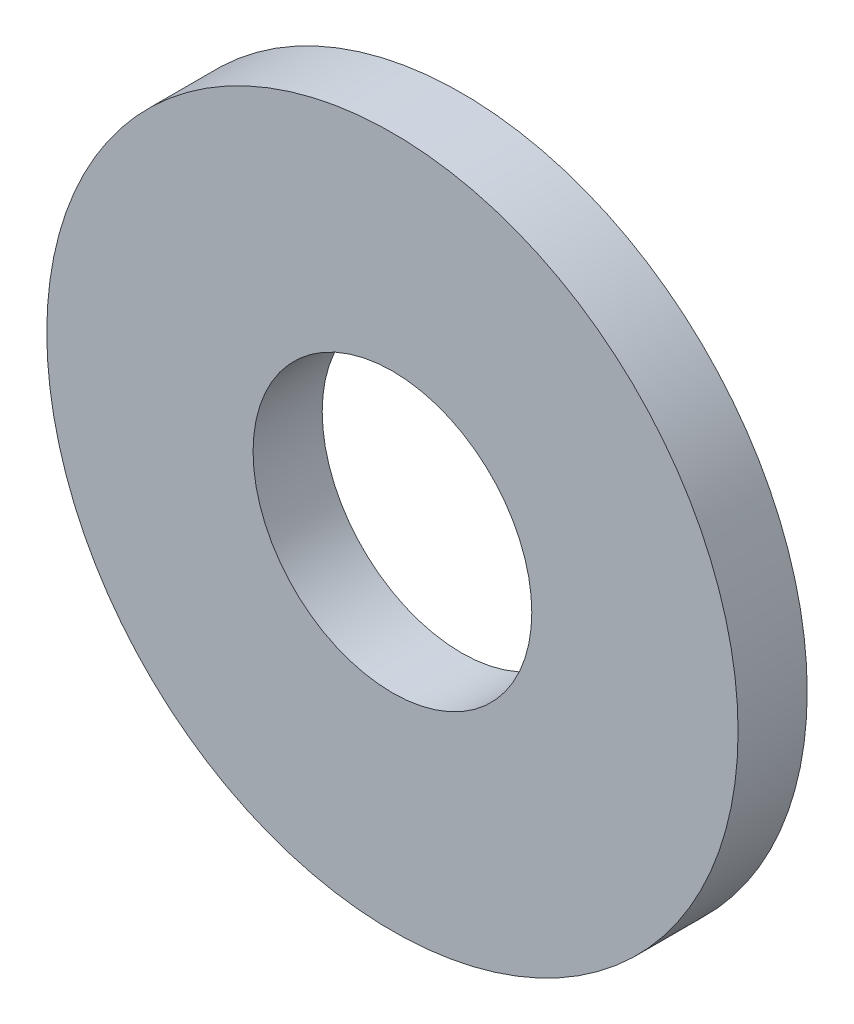
from build123d import *

# Parameters (mm, degrees)
SKETCH1_R      = 7.9375
SKETCH1_R_2    = 3.2004
EXTRUDE1_DEPTH = 0.79375


with BuildPart() as part:
    # Sketch1 → Extrude1 (new body, symmetric)
    with BuildSketch(Plane.XY):
        Circle(SKETCH1_R)
        Circle(SKETCH1_R_2, mode=Mode.SUBTRACT)
    extrude(amount=EXTRUDE1_DEPTH, both=True)


solid = part.part
